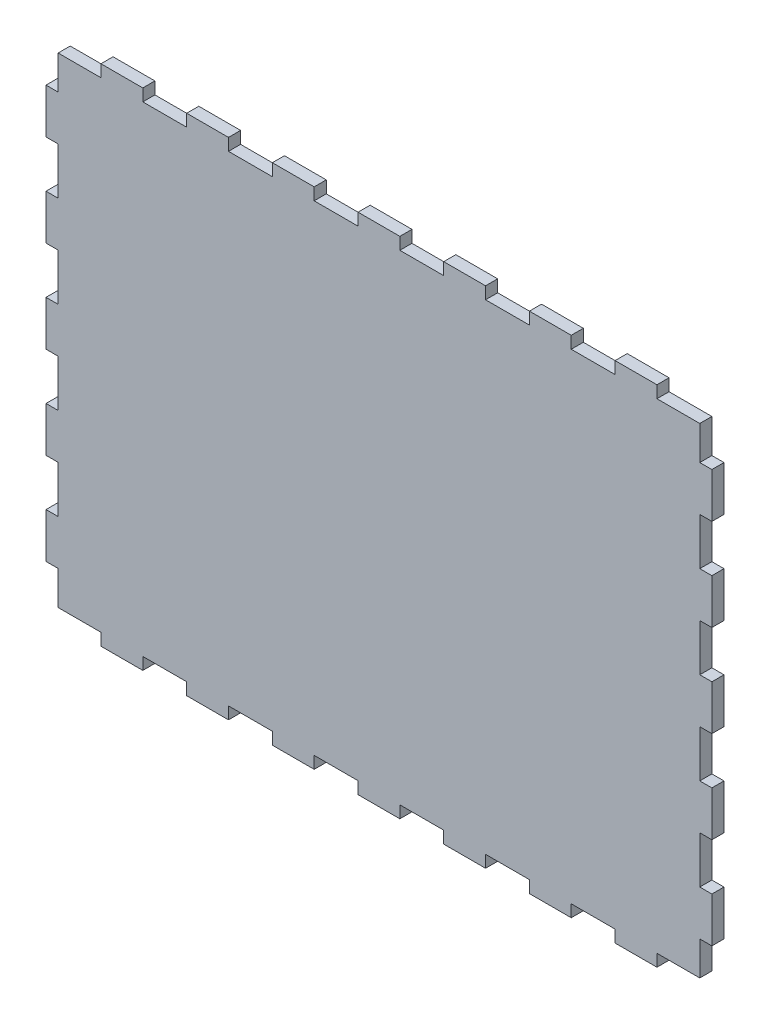
from build123d import *

# Parameters (mm, degrees)
BOSS_EXTRUDE1_DEPTH = 6


with BuildPart() as part:
    # Sketch1 → Boss-Extrude1 (new body)
    with BuildSketch(Plane.XY.offset(6)):
        Polygon((302.766666667, 244), (302.766666667, 250), (282.033333333, 250), (282.033333333, 244), (260.3, 244), (260.3, 250), (239.566666667, 250), (239.566666667, 244), (217.833333333, 244), (217.833333333, 250), (197.1, 250), (197.1, 244), (175.366666667, 244), (175.366666667, 250), (154.633333333, 250), (154.633333333, 244), (132.9, 244), (132.9, 250), (112.166666667, 250), (112.166666667, 244), (90.433333333, 244), (90.433333333, 250), (69.7, 250), (69.7, 244), (47.966666667, 244), (47.966666667, 250), (27.233333333, 250), (27.233333333, 244), (6, 244), (6, 227.227272727), (0, 227.227272727), (0, 204.954545455), (6, 204.954545455), (6, 181.681818182), (0, 181.681818182), (0, 159.409090909), (6, 159.409090909), (6, 136.136363636), (0, 136.136363636), (0, 113.863636364), (6, 113.863636364), (6, 90.590909091), (0, 90.590909091), (0, 68.318181818), (6, 68.318181818), (6, 45.045454545), (0, 45.045454545), (0, 22.772727273), (6, 22.772727273), (6, 6), (27.233333333, 6), (27.233333333, 0), (47.966666667, 0), (47.966666667, 6), (69.7, 6), (69.7, 0), (90.433333333, 0), (90.433333333, 6), (112.166666667, 6), (112.166666667, 0), (132.9, 0), (132.9, 6), (154.633333333, 6), (154.633333333, 0), (175.366666667, 0), (175.366666667, 6), (197.1, 6), (197.1, 0), (217.833333333, 0), (217.833333333, 6), (239.566666667, 6), (239.566666667, 0), (260.3, 0), (260.3, 6), (282.033333333, 6), (282.033333333, 0), (302.766666667, 0), (302.766666667, 6), (324, 6), (324, 22.772727273), (330, 22.772727273), (330, 45.045454545), (324, 45.045454545), (324, 68.318181818), (330, 68.318181818), (330, 90.590909091), (324, 90.590909091), (324, 113.863636364), (330, 113.863636364), (330, 136.136363636), (324, 136.136363636), (324, 159.409090909), (330, 159.409090909), (330, 181.681818182), (324, 181.681818182), (324, 204.954545455), (330, 204.954545455), (330, 227.227272727), (324, 227.227272727), (324, 244), align=None)
    extrude(amount=-BOSS_EXTRUDE1_DEPTH)


solid = part.part
